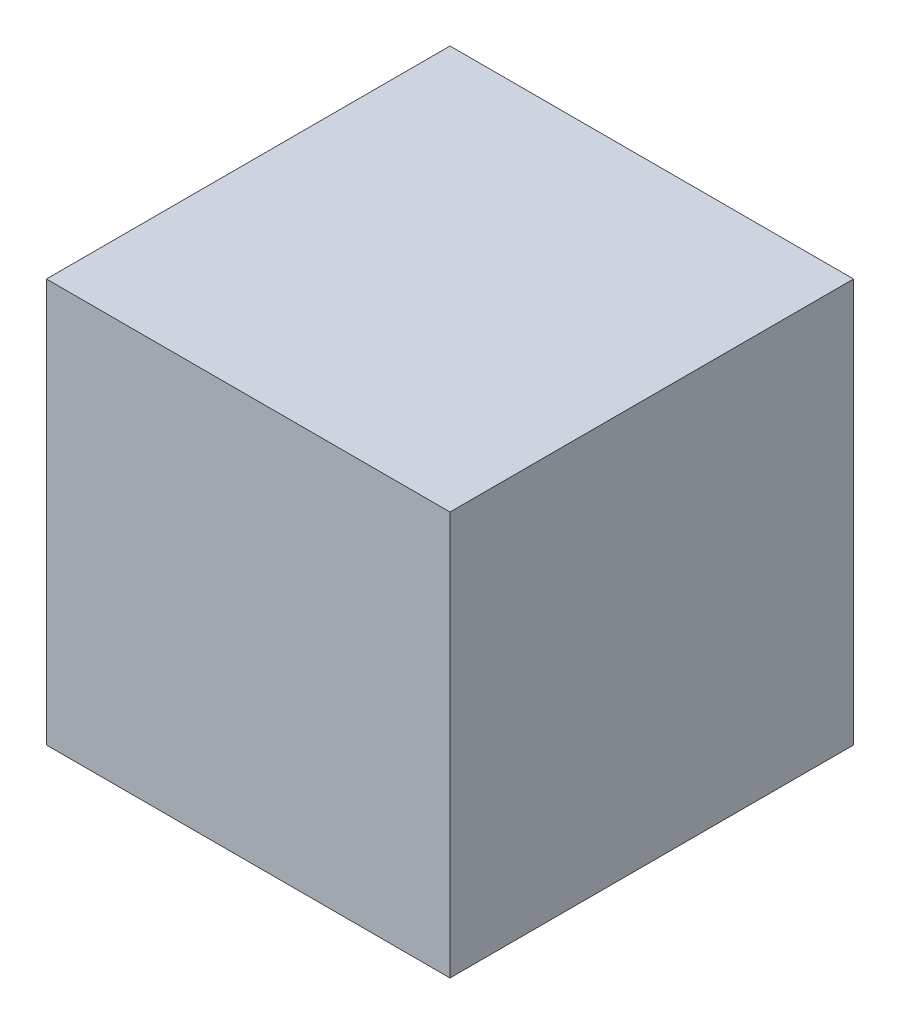
from build123d import *

# Parameters (mm, degrees)
ESQUISSE1_W        = 100
ESQUISSE1_H        = 100
BOSS_EXTRU_1_DEPTH = 100


with BuildPart() as part:
    # Esquisse1 → Boss.-Extru.1 (new body)
    with BuildSketch(Plane.XY):
        with Locations((50, 50)):
            Rectangle(ESQUISSE1_W, ESQUISSE1_H)
    extrude(amount=BOSS_EXTRU_1_DEPTH)


solid = part.part
